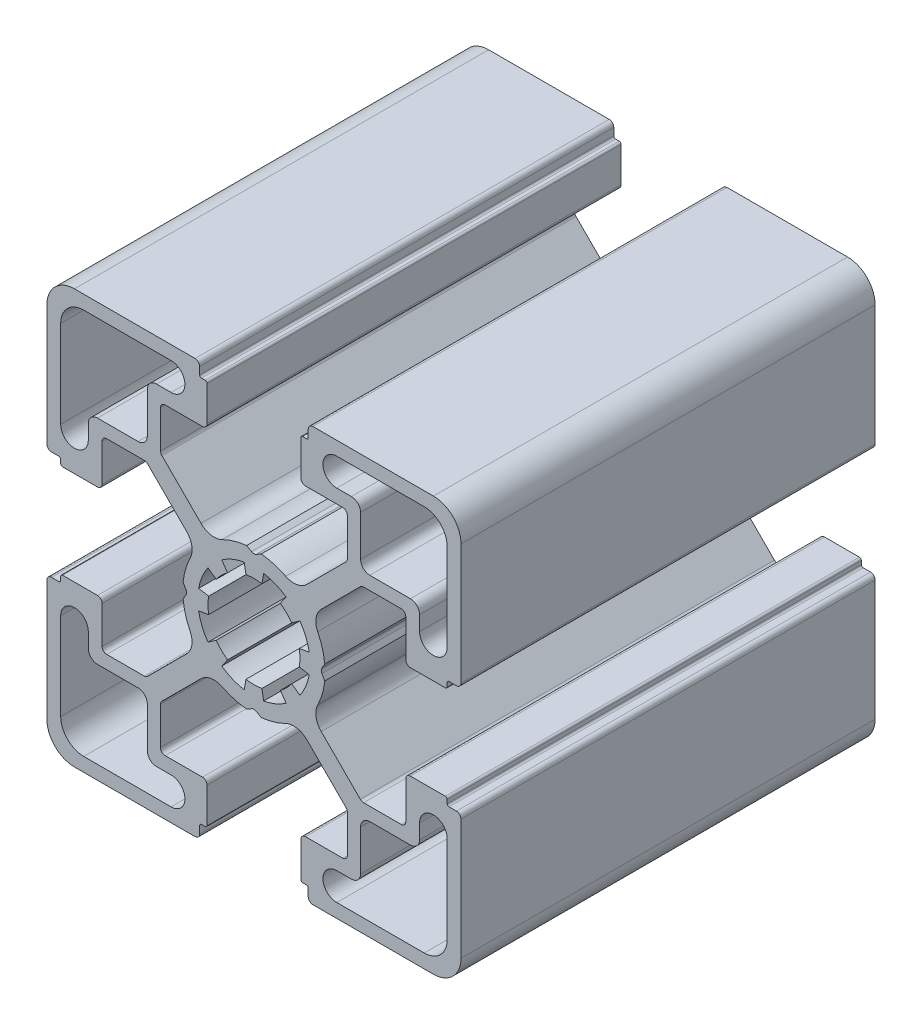
from build123d import *

# Parameters (mm, degrees)
EXTRUDE_1_DEPTH = 45


with BuildPart() as part:
    # Эскиз1 → Бобышка-Вытянуть1 (new body)
    with BuildSketch(Plane.XY):
        with BuildLine():
            Line((-7.385758924, -0.25), (-7.700480433, -0.795113645))
            ThreePointArc((-7.700480433, -0.795113645), (-7.43518013, -2.155852742), (-6.931427059, -3.447451745))
            ThreePointArc((-6.931427059, -3.447451745), (-6.748328792, -4.660549584), (-7.307951074, -5.752316155))
            Line((-7.307951074, -5.752316155), (-7.887867966, -6.332233047))
            Line((-7.887867966, -6.332233047), (-11.559188309, -10.003553391))
            ThreePointArc((-11.559188309, -10.003553391), (-11.721399984, -10.111939766), (-11.9127417, -10.15))
            Line((-11.9127417, -10.15), (-16, -10.15))
            ThreePointArc((-16, -10.15), (-16.353553391, -10.003553391), (-16.5, -9.65))
            Line((-16.5, -9.65), (-16.5, -5.6))
            ThreePointArc((-16.5, -5.6), (-16.646446609, -5.246446609), (-17, -5.1))
            Line((-17, -5.1), (-20.8, -5.1))
            ThreePointArc((-20.8, -5.1), (-20.941421356, -5.158578644), (-21, -5.3))
            Line((-21, -5.3), (-21, -5.7))
            ThreePointArc((-21, -5.7), (-21.058578644, -5.841421356), (-21.2, -5.9))
            Line((-21.2, -5.9), (-22, -5.9))
            ThreePointArc((-22, -5.9), (-22.353553391, -6.046446609), (-22.5, -6.4))
            Line((-22.5, -6.4), (-22.5, -19.5))
            ThreePointArc((-22.5, -19.5), (-21.621320344, -21.621320344), (-19.5, -22.5))
            Line((-19.5, -22.5), (-6.4, -22.5))
            ThreePointArc((-6.4, -22.5), (-6.046446609, -22.353553391), (-5.9, -22))
            Line((-5.9, -22), (-5.9, -21.2))
            ThreePointArc((-5.9, -21.2), (-5.841421356, -21.058578644), (-5.7, -21))
            Line((-5.7, -21), (-5.3, -21))
            ThreePointArc((-5.3, -21), (-5.158578644, -20.941421356), (-5.1, -20.8))
            Line((-5.1, -20.8), (-5.1, -17))
            ThreePointArc((-5.1, -17), (-5.246446609, -16.646446609), (-5.6, -16.5))
            Line((-5.6, -16.5), (-9.65, -16.5))
            ThreePointArc((-9.65, -16.5), (-10.003553391, -16.353553391), (-10.15, -16))
            Line((-10.15, -16), (-10.15, -11.9127417))
            ThreePointArc((-10.15, -11.9127417), (-10.111939766, -11.721399984), (-10.003553391, -11.559188309))
            Line((-10.003553391, -11.559188309), (-6.332233047, -7.887867966))
            Line((-6.332233047, -7.887867966), (-5.752316155, -7.307951074))
            ThreePointArc((-5.752316155, -7.307951074), (-4.660549584, -6.748328792), (-3.447451745, -6.931427059))
            ThreePointArc((-3.447451745, -6.931427059), (-2.155852742, -7.43518013), (-0.795113645, -7.700480433))
            Line((-0.795113645, -7.700480433), (-0.25, -7.385758924))
            ThreePointArc((-0.25, -7.385758924), (0, -7.318771625), (0.25, -7.385758924))
            Line((0.25, -7.385758924), (0.795113645, -7.700480433))
            ThreePointArc((0.795113645, -7.700480433), (2.155852742, -7.43518013), (3.447451745, -6.931427059))
            ThreePointArc((3.447451745, -6.931427059), (4.660549584, -6.748328792), (5.752316155, -7.307951074))
            Line((5.752316155, -7.307951074), (6.332233047, -7.887867966))
            Line((6.332233047, -7.887867966), (10.003553391, -11.559188309))
            ThreePointArc((10.003553391, -11.559188309), (10.111939766, -11.721399984), (10.15, -11.9127417))
            Line((10.15, -11.9127417), (10.15, -16))
            ThreePointArc((10.15, -16), (10.003553391, -16.353553391), (9.65, -16.5))
            Line((9.65, -16.5), (5.6, -16.5))
            ThreePointArc((5.6, -16.5), (5.246446609, -16.646446609), (5.1, -17))
            Line((5.1, -17), (5.1, -20.8))
            ThreePointArc((5.1, -20.8), (5.158578644, -20.941421356), (5.3, -21))
            Line((5.3, -21), (5.7, -21))
            ThreePointArc((5.7, -21), (5.841421356, -21.058578644), (5.9, -21.2))
            Line((5.9, -21.2), (5.9, -22))
            ThreePointArc((5.9, -22), (6.046446609, -22.353553391), (6.4, -22.5))
            Line((6.4, -22.5), (19.5, -22.5))
            ThreePointArc((19.5, -22.5), (21.621320344, -21.621320344), (22.5, -19.5))
            Line((22.5, -19.5), (22.5, -6.4))
            ThreePointArc((22.5, -6.4), (22.353553391, -6.046446609), (22, -5.9))
            Line((22, -5.9), (21.2, -5.9))
            ThreePointArc((21.2, -5.9), (21.058578644, -5.841421356), (21, -5.7))
            Line((21, -5.7), (21, -5.3))
            ThreePointArc((21, -5.3), (20.941421356, -5.158578644), (20.8, -5.1))
            Line((20.8, -5.1), (17, -5.1))
            ThreePointArc((17, -5.1), (16.646446609, -5.246446609), (16.5, -5.6))
            Line((16.5, -5.6), (16.5, -9.65))
            ThreePointArc((16.5, -9.65), (16.353553391, -10.003553391), (16, -10.15))
            Line((16, -10.15), (11.9127417, -10.15))
            ThreePointArc((11.9127417, -10.15), (11.721399984, -10.111939766), (11.559188309, -10.003553391))
            Line((11.559188309, -10.003553391), (7.887867966, -6.332233047))
            Line((7.887867966, -6.332233047), (7.307951074, -5.752316155))
            ThreePointArc((7.307951074, -5.752316155), (6.748328792, -4.660549584), (6.931427059, -3.447451745))
            ThreePointArc((6.931427059, -3.447451745), (7.43518013, -2.155852742), (7.700480433, -0.795113645))
            Line((7.700480433, -0.795113645), (7.385758924, -0.25))
            ThreePointArc((7.385758924, -0.25), (7.318771625, 0), (7.385758924, 0.25))
            Line((7.385758924, 0.25), (7.700480433, 0.795113645))
            ThreePointArc((7.700480433, 0.795113645), (7.43518013, 2.155852742), (6.931427059, 3.447451745))
            ThreePointArc((6.931427059, 3.447451745), (6.748328792, 4.660549584), (7.307951074, 5.752316155))
            Line((7.307951074, 5.752316155), (7.887867966, 6.332233047))
            Line((7.887867966, 6.332233047), (11.559188309, 10.003553391))
            ThreePointArc((11.559188309, 10.003553391), (11.721399984, 10.111939766), (11.9127417, 10.15))
            Line((11.9127417, 10.15), (16, 10.15))
            ThreePointArc((16, 10.15), (16.353553391, 10.003553391), (16.5, 9.65))
            Line((16.5, 9.65), (16.5, 5.6))
            ThreePointArc((16.5, 5.6), (16.646446609, 5.246446609), (17, 5.1))
            Line((17, 5.1), (20.8, 5.1))
            ThreePointArc((20.8, 5.1), (20.941421356, 5.158578644), (21, 5.3))
            Line((21, 5.3), (21, 5.7))
            ThreePointArc((21, 5.7), (21.058578644, 5.841421356), (21.2, 5.9))
            Line((21.2, 5.9), (22, 5.9))
            ThreePointArc((22, 5.9), (22.353553391, 6.046446609), (22.5, 6.4))
            Line((22.5, 6.4), (22.5, 19.5))
            ThreePointArc((22.5, 19.5), (21.621320344, 21.621320344), (19.5, 22.5))
            Line((19.5, 22.5), (6.4, 22.5))
            ThreePointArc((6.4, 22.5), (6.046446609, 22.353553391), (5.9, 22))
            Line((5.9, 22), (5.9, 21.2))
            ThreePointArc((5.9, 21.2), (5.841421356, 21.058578644), (5.7, 21))
            Line((5.7, 21), (5.3, 21))
            ThreePointArc((5.3, 21), (5.158578644, 20.941421356), (5.1, 20.8))
            Line((5.1, 20.8), (5.1, 17))
            ThreePointArc((5.1, 17), (5.246446609, 16.646446609), (5.6, 16.5))
            Line((5.6, 16.5), (9.65, 16.5))
            ThreePointArc((9.65, 16.5), (10.003553391, 16.353553391), (10.15, 16))
            Line((10.15, 16), (10.15, 11.9127417))
            ThreePointArc((10.15, 11.9127417), (10.111939766, 11.721399984), (10.003553391, 11.559188309))
            Line((10.003553391, 11.559188309), (6.332233047, 7.887867966))
            Line((6.332233047, 7.887867966), (5.752316155, 7.307951074))
            ThreePointArc((5.752316155, 7.307951074), (4.660549584, 6.748328792), (3.447451745, 6.931427059))
            ThreePointArc((3.447451745, 6.931427059), (2.155852742, 7.43518013), (0.795113645, 7.700480433))
            Line((0.795113645, 7.700480433), (0.25, 7.385758924))
            ThreePointArc((0.25, 7.385758924), (0, 7.318771625), (-0.25, 7.385758924))
            Line((-0.25, 7.385758924), (-0.795113645, 7.700480433))
            ThreePointArc((-0.795113645, 7.700480433), (-2.155852742, 7.43518013), (-3.447451745, 6.931427059))
            ThreePointArc((-3.447451745, 6.931427059), (-4.660549584, 6.748328792), (-5.752316155, 7.307951074))
            Line((-5.752316155, 7.307951074), (-6.332233047, 7.887867966))
            Line((-6.332233047, 7.887867966), (-10.003553391, 11.559188309))
            ThreePointArc((-10.003553391, 11.559188309), (-10.111939766, 11.721399984), (-10.15, 11.9127417))
            Line((-10.15, 11.9127417), (-10.15, 16))
            ThreePointArc((-10.15, 16), (-10.003553391, 16.353553391), (-9.65, 16.5))
            Line((-9.65, 16.5), (-5.6, 16.5))
            ThreePointArc((-5.6, 16.5), (-5.246446609, 16.646446609), (-5.1, 17))
            Line((-5.1, 17), (-5.1, 20.8))
            ThreePointArc((-5.1, 20.8), (-5.158578644, 20.941421356), (-5.3, 21))
            Line((-5.3, 21), (-5.7, 21))
            ThreePointArc((-5.7, 21), (-5.841421356, 21.058578644), (-5.9, 21.2))
            Line((-5.9, 21.2), (-5.9, 22))
            ThreePointArc((-5.9, 22), (-6.046446609, 22.353553391), (-6.4, 22.5))
            Line((-6.4, 22.5), (-19.5, 22.5))
            ThreePointArc((-19.5, 22.5), (-21.621320344, 21.621320344), (-22.5, 19.5))
            Line((-22.5, 19.5), (-22.5, 6.4))
            ThreePointArc((-22.5, 6.4), (-22.353553391, 6.046446609), (-22, 5.9))
            Line((-22, 5.9), (-21.2, 5.9))
            ThreePointArc((-21.2, 5.9), (-21.058578644, 5.841421356), (-21, 5.7))
            Line((-21, 5.7), (-21, 5.3))
            ThreePointArc((-21, 5.3), (-20.941421356, 5.158578644), (-20.8, 5.1))
            Line((-20.8, 5.1), (-17, 5.1))
            ThreePointArc((-17, 5.1), (-16.646446609, 5.246446609), (-16.5, 5.6))
            Line((-16.5, 5.6), (-16.5, 9.65))
            ThreePointArc((-16.5, 9.65), (-16.353553391, 10.003553391), (-16, 10.15))
            Line((-16, 10.15), (-11.9127417, 10.15))
            ThreePointArc((-11.9127417, 10.15), (-11.721399984, 10.111939766), (-11.559188309, 10.003553391))
            Line((-11.559188309, 10.003553391), (-7.887867966, 6.332233047))
            Line((-7.887867966, 6.332233047), (-7.307951074, 5.752316155))
            ThreePointArc((-7.307951074, 5.752316155), (-6.748328792, 4.660549584), (-6.931427059, 3.447451745))
            ThreePointArc((-6.931427059, 3.447451745), (-7.43518013, 2.155852742), (-7.700480433, 0.795113645))
            Line((-7.700480433, 0.795113645), (-7.385758924, 0.25))
            ThreePointArc((-7.385758924, 0.25), (-7.318771625, 0), (-7.385758924, -0.25))
        make_face()
        with BuildLine():
            Line((11.59, -14.67575672), (11.59, -12.59))
            ThreePointArc((11.59, -12.59), (11.882893219, -11.882893219), (12.59, -11.59))
            Line((12.59, -11.59), (14.67575672, -11.59))
            Line((14.67575672, -11.59), (17, -11.59))
            ThreePointArc((17, -11.59), (17.707106781, -11.297106781), (18, -10.59))
            Line((18, -10.59), (18, -9))
            ThreePointArc((18, -9), (19.5, -7.5), (21, -9))
            Line((21, -9), (21, -18.5))
            ThreePointArc((21, -18.5), (20.267766953, -20.267766953), (18.5, -21))
            Line((18.5, -21), (9, -21))
            ThreePointArc((9, -21), (7.5, -19.5), (9, -18))
            Line((9, -18), (10.59, -18))
            ThreePointArc((10.59, -18), (11.297106781, -17.707106781), (11.59, -17))
            Line((11.59, -17), (11.59, -14.67575672))
        make_face(mode=Mode.SUBTRACT)
        with BuildLine():
            Line((18.5, 21), (9, 21))
            ThreePointArc((9, 21), (7.5, 19.5), (9, 18))
            Line((9, 18), (10.59, 18))
            ThreePointArc((10.59, 18), (11.297106781, 17.707106781), (11.59, 17))
            Line((11.59, 17), (11.59, 14.67575672))
            Line((11.59, 14.67575672), (11.59, 12.59))
            ThreePointArc((11.59, 12.59), (11.882893219, 11.882893219), (12.59, 11.59))
            Line((12.59, 11.59), (14.67575672, 11.59))
            Line((14.67575672, 11.59), (17, 11.59))
            ThreePointArc((17, 11.59), (17.707106781, 11.297106781), (18, 10.59))
            Line((18, 10.59), (18, 9))
            ThreePointArc((18, 9), (19.5, 7.5), (21, 9))
            Line((21, 9), (21, 18.5))
            ThreePointArc((21, 18.5), (20.267766953, 20.267766953), (18.5, 21))
        make_face(mode=Mode.SUBTRACT)
        with BuildLine():
            Line((-11.59, 14.67575672), (-11.59, 12.59))
            ThreePointArc((-11.59, 12.59), (-11.882893219, 11.882893219), (-12.59, 11.59))
            Line((-12.59, 11.59), (-14.67575672, 11.59))
            Line((-14.67575672, 11.59), (-17, 11.59))
            ThreePointArc((-17, 11.59), (-17.707106781, 11.297106781), (-18, 10.59))
            Line((-18, 10.59), (-18, 9))
            ThreePointArc((-18, 9), (-19.5, 7.5), (-21, 9))
            Line((-21, 9), (-21, 18.5))
            ThreePointArc((-21, 18.5), (-20.267766953, 20.267766953), (-18.5, 21))
            Line((-18.5, 21), (-9, 21))
            ThreePointArc((-9, 21), (-7.5, 19.5), (-9, 18))
            Line((-9, 18), (-10.59, 18))
            ThreePointArc((-10.59, 18), (-11.297106781, 17.707106781), (-11.59, 17))
            Line((-11.59, 17), (-11.59, 14.67575672))
        make_face(mode=Mode.SUBTRACT)
        with BuildLine():
            Line((-2.867882182, 4.095760221), (-3.498816262, 4.99682747))
            ThreePointArc((-3.498816262, 4.99682747), (-2.334368937, 5.635665148), (-1.059253884, 6.007327293))
            Line((-1.059253884, 6.007327293), (-0.868240888, 4.924038765))
            ThreePointArc((-0.868240888, 4.924038765), (0, 5), (0.868240888, 4.924038765))
            Line((0.868240888, 4.924038765), (1.059253884, 6.007327293))
            ThreePointArc((1.059253884, 6.007327293), (2.334368937, 5.635665148), (3.498816262, 4.99682747))
            Line((3.498816262, 4.99682747), (2.867882182, 4.095760221))
            ThreePointArc((2.867882182, 4.095760221), (3.535533906, 3.535533906), (4.095760221, 2.867882182))
            Line((4.095760221, 2.867882182), (4.99682747, 3.498816262))
            ThreePointArc((4.99682747, 3.498816262), (5.635665148, 2.334368937), (6.007327293, 1.059253884))
            Line((6.007327293, 1.059253884), (4.924038765, 0.868240888))
            ThreePointArc((4.924038765, 0.868240888), (5, 0), (4.924038765, -0.868240888))
            Line((4.924038765, -0.868240888), (6.007327293, -1.059253884))
            ThreePointArc((6.007327293, -1.059253884), (5.635665148, -2.334368937), (4.99682747, -3.498816262))
            Line((4.99682747, -3.498816262), (4.095760221, -2.867882182))
            ThreePointArc((4.095760221, -2.867882182), (3.535533906, -3.535533906), (2.867882182, -4.095760221))
            Line((2.867882182, -4.095760221), (3.498816262, -4.99682747))
            ThreePointArc((3.498816262, -4.99682747), (2.334368937, -5.635665148), (1.059253884, -6.007327293))
            Line((1.059253884, -6.007327293), (0.868240888, -4.924038765))
            ThreePointArc((0.868240888, -4.924038765), (0, -5), (-0.868240888, -4.924038765))
            Line((-0.868240888, -4.924038765), (-1.059253884, -6.007327293))
            ThreePointArc((-1.059253884, -6.007327293), (-2.334368937, -5.635665148), (-3.498816262, -4.99682747))
            Line((-3.498816262, -4.99682747), (-2.867882182, -4.095760221))
            ThreePointArc((-2.867882182, -4.095760221), (-3.535533906, -3.535533906), (-4.095760221, -2.867882182))
            Line((-4.095760221, -2.867882182), (-4.99682747, -3.498816262))
            ThreePointArc((-4.99682747, -3.498816262), (-5.635665148, -2.334368937), (-6.007327293, -1.059253884))
            Line((-6.007327293, -1.059253884), (-4.924038765, -0.868240888))
            ThreePointArc((-4.924038765, -0.868240888), (-5, 0), (-4.924038765, 0.868240888))
            Line((-4.924038765, 0.868240888), (-6.007327293, 1.059253884))
            ThreePointArc((-6.007327293, 1.059253884), (-5.635665148, 2.334368937), (-4.99682747, 3.498816262))
            Line((-4.99682747, 3.498816262), (-4.095760221, 2.867882182))
            ThreePointArc((-4.095760221, 2.867882182), (-3.535533906, 3.535533906), (-2.867882182, 4.095760221))
        make_face(mode=Mode.SUBTRACT)
        with BuildLine():
            Line((-18.5, -21), (-9, -21))
            ThreePointArc((-9, -21), (-7.5, -19.5), (-9, -18))
            Line((-9, -18), (-10.59, -18))
            ThreePointArc((-10.59, -18), (-11.297106781, -17.707106781), (-11.59, -17))
            Line((-11.59, -17), (-11.59, -14.67575672))
            Line((-11.59, -14.67575672), (-11.59, -12.59))
            ThreePointArc((-11.59, -12.59), (-11.882893219, -11.882893219), (-12.59, -11.59))
            Line((-12.59, -11.59), (-14.67575672, -11.59))
            Line((-14.67575672, -11.59), (-17, -11.59))
            ThreePointArc((-17, -11.59), (-17.707106781, -11.297106781), (-18, -10.59))
            Line((-18, -10.59), (-18, -9))
            ThreePointArc((-18, -9), (-19.5, -7.5), (-21, -9))
            Line((-21, -9), (-21, -18.5))
            ThreePointArc((-21, -18.5), (-20.267766953, -20.267766953), (-18.5, -21))
        make_face(mode=Mode.SUBTRACT)
    extrude(amount=EXTRUDE_1_DEPTH)


solid = part.part
